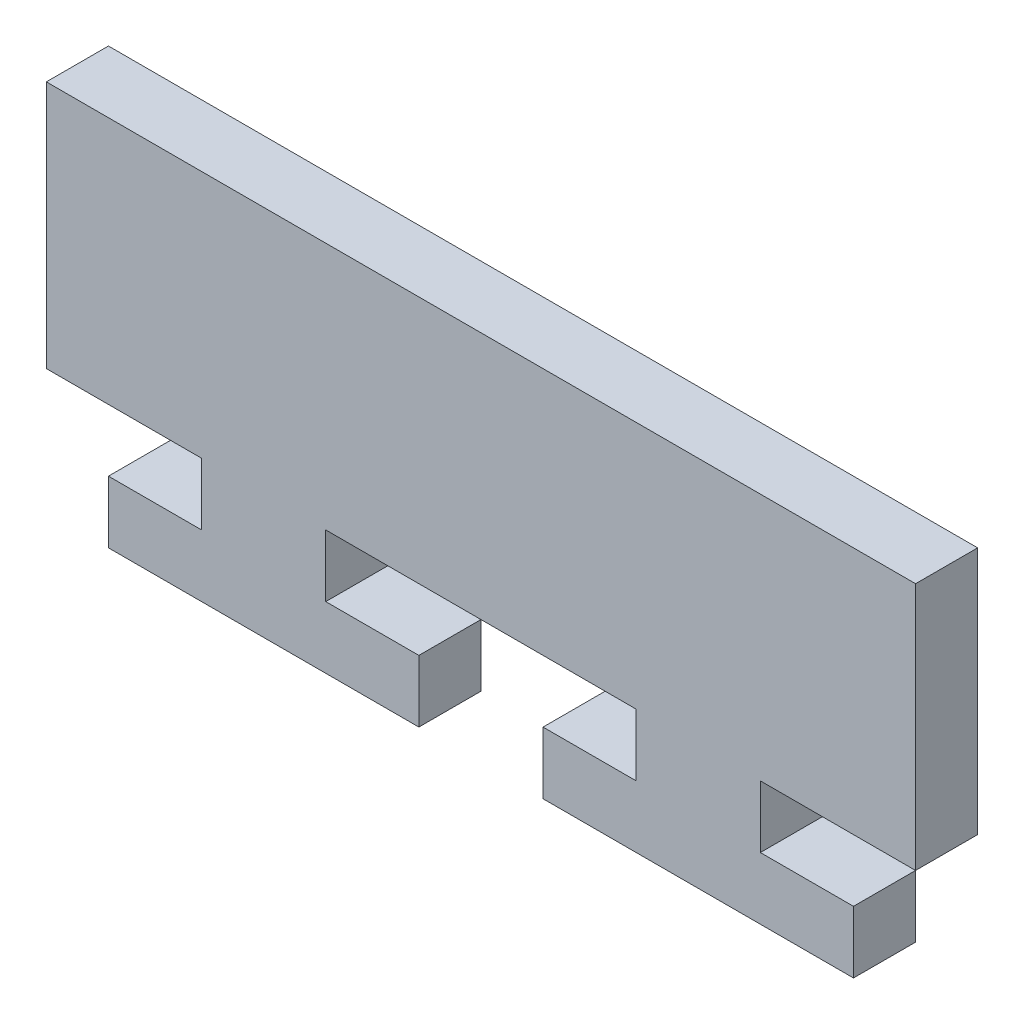
from build123d import *

# Parameters (mm, degrees)
BOSS_EXTRU_1_DEPTH = 5


with BuildPart() as part:
    # Esquisse1 → Boss.-Extru.1 (new body)
    with BuildSketch(Plane.XY):
        Polygon((-35, -10), (-22.5, -10), (-22.5, -15), (-30, -15), (-30, -20), (-5, -20), (-5, -15), (-12.5, -15), (-12.5, -10), (12.5, -10), (12.5, -15), (5, -15), (5, -20), (30, -20), (30, -15), (22.5, -15), (22.5, -10), (35, -10), (35, 10), (-35, 10), align=None)
    extrude(amount=BOSS_EXTRU_1_DEPTH)


solid = part.part
